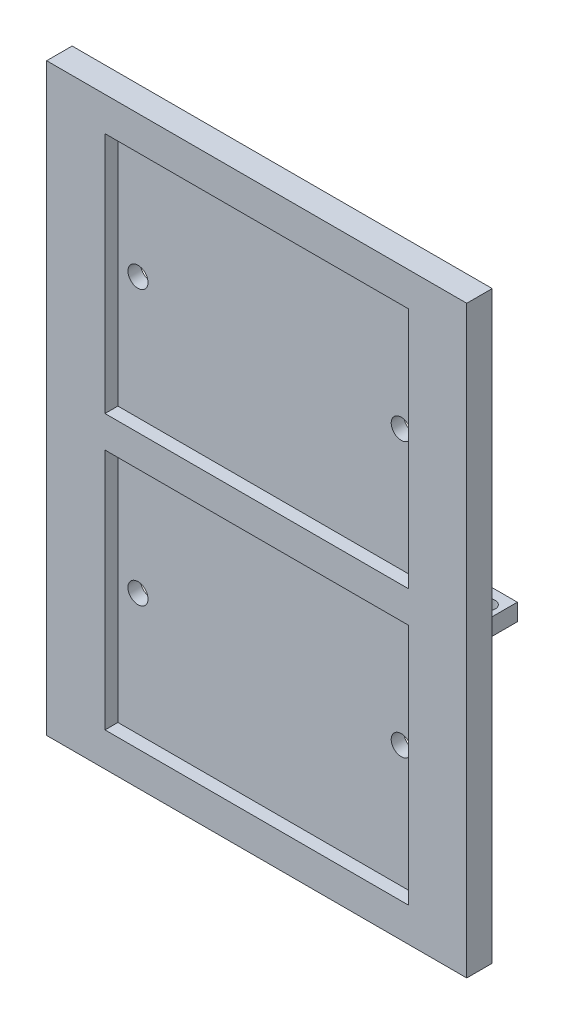
from build123d import *

# Parameters (mm, degrees)
SKETCH12_W          = 62.8142
SKETCH12_H          = 87.376
BOSS_EXTRUDE5_DEPTH = 3.81
SKETCH22_W          = 3.81
SKETCH22_H          = 2.54
BOSS_EXTRUDE6_DEPTH = 5.08
SKETCH23_R          = 1.1303
CUT_EXTRUDE5_DEPTH  = 5.08
SKETCH25_W          = 45.3644
SKETCH25_H          = 36.2458
CUT_EXTRUDE6_DEPTH  = 1.9304
SKETCH26_R          = 1.5
CUT_EXTRUDE7_DEPTH  = 1.9304


with BuildPart() as part:
    # Sketch12 → Boss-Extrude5 (new body)
    with BuildSketch(Plane.XY):
        Rectangle(SKETCH12_W, SKETCH12_H)
    extrude(amount=-BOSS_EXTRUDE5_DEPTH)

    # Sketch22 → Boss-Extrude6 (add)
    with BuildSketch(Plane(origin=(0, 0, -3.81), x_dir=(-1, 0, 0), z_dir=(0, 0, -1))):
        with Locations((-28.1803602, -1.397)):
            Rectangle(SKETCH22_W, SKETCH22_H)
        with Locations((28.1803602, -1.397)):
            Rectangle(SKETCH22_W, SKETCH22_H)
    extrude(amount=BOSS_EXTRUDE6_DEPTH)

    # Sketch23 → Cut-Extrude5 (cut)
    with BuildSketch(Plane(origin=(0, -0.127, 0), x_dir=(1, 0, 0), z_dir=(0, 1, 0))):
        with Locations((28.1803602, 6.35)):
            Circle(SKETCH23_R)
        with Locations((-28.362608627, 6.35)):
            Circle(SKETCH23_R)
    extrude(amount=-CUT_EXTRUDE5_DEPTH, mode=Mode.SUBTRACT)

    # Sketch25 → Cut-Extrude6 (cut)
    with BuildSketch(Plane.XY):
        with Locations((0, 20.4851)):
            Rectangle(SKETCH25_W, SKETCH25_H)
        with Locations((0, -20.4851)):
            Rectangle(SKETCH25_W, SKETCH25_H)
    extrude(amount=-CUT_EXTRUDE6_DEPTH, mode=Mode.SUBTRACT)

    # Sketch26 → Cut-Extrude7 (cut)
    with BuildSketch(Plane.XY.offset(-1.9304)):
        with Locations((19.6822, 20.608)):
            Circle(SKETCH26_R)
        with Locations((19.6822, -20.3622)):
            Circle(SKETCH26_R)
        with Locations((-19.6822, -20.3622)):
            Circle(SKETCH26_R)
        with Locations((-19.6822, 20.608)):
            Circle(SKETCH26_R)
    extrude(amount=-CUT_EXTRUDE7_DEPTH, mode=Mode.SUBTRACT)


solid = part.part
